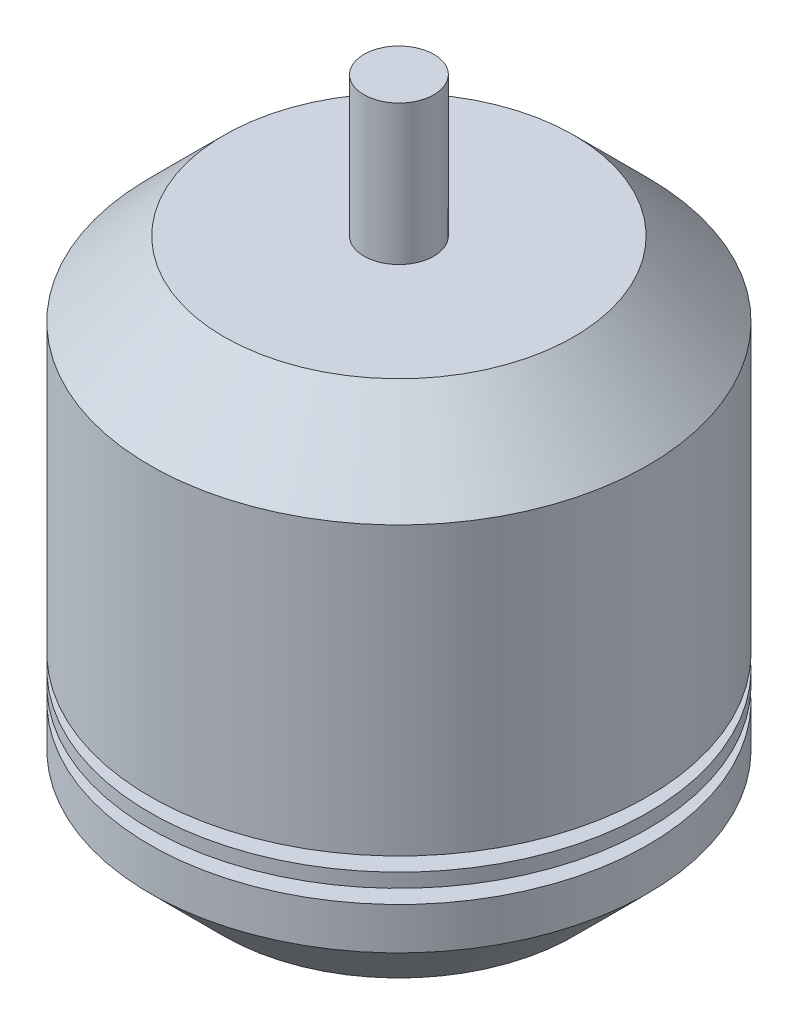
from build123d import *


with BuildPart() as part:
    # Sketch1 → Revolve1 (revolve)
    with BuildSketch(Plane.XY):
        Polygon((6.35, -2.195764302), (63.5, -2.195764302), (90.440768363, 24.745004061), (90.440768363, 39.985004061), (80.280768363, 39.985004061), (80.280768363, 45.065004061), (90.440768363, 45.065004061), (90.440768363, 50.145004061), (80.280768363, 50.145004061), (80.280768363, 55.225004061), (90.440768363, 55.225004061), (90.440768363, 159.365004061), (63.5, 186.305772424), (12.7, 186.305772424), (12.7, 237.105772424), (0, 237.105772424), (0, 0), (0, -25.4650148), (6.35, -25.4650148), align=None)
        Polygon((22.967294816, 176.145772424), (62.500768363, 176.145772424), (80.280768363, 158.365772424), (80.280768363, 140.585772424), (12.807294816, 140.585772424), (12.807294816, 165.985772424), (22.967294816, 165.985772424), align=None, mode=Mode.SUBTRACT)
    revolve(axis=Axis((0, 237.105772424, 0), (0, 1, 0)))


solid = part.part
